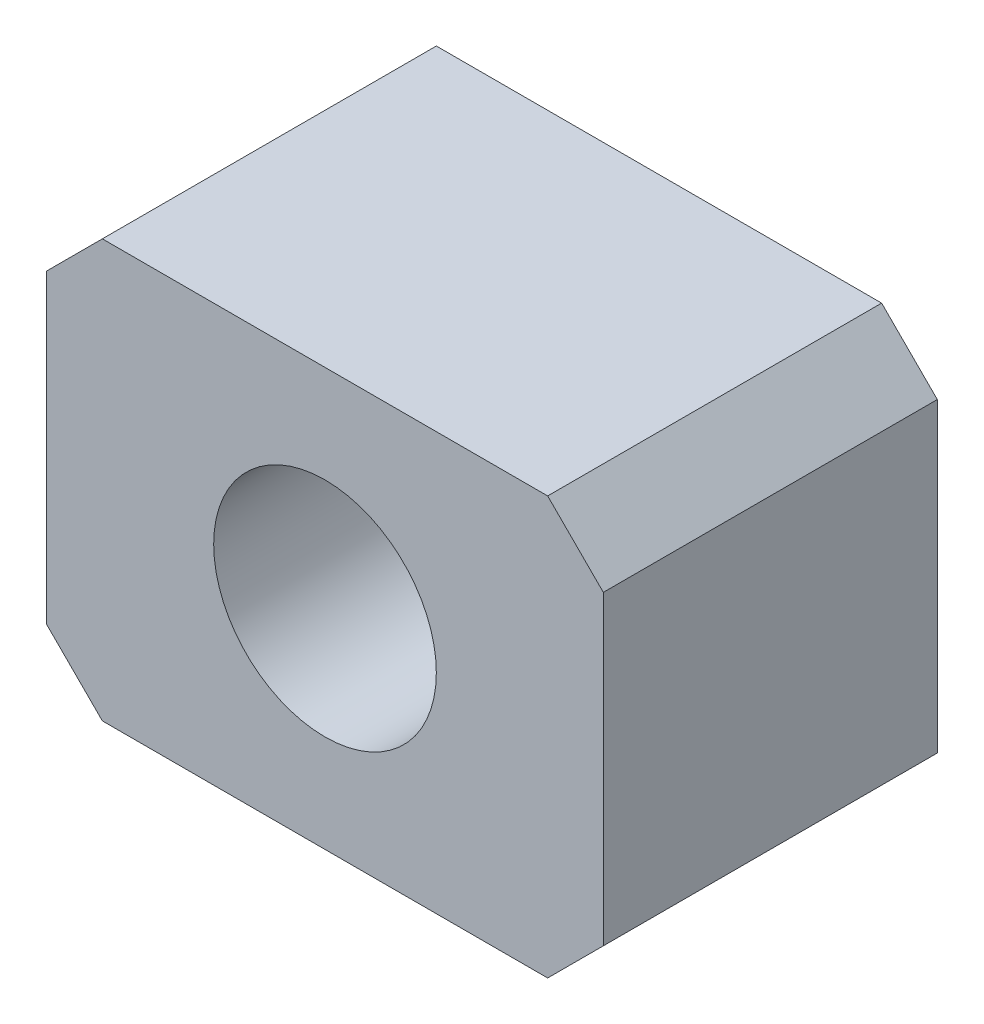
from build123d import *

# Parameters (mm, degrees)
SKETCH1_W           = 20
SKETCH1_H           = 15
BOSS_EXTRUDE1_DEPTH = 12
SKETCH2_R           = 4
CUT_EXTRUDE1_DEPTH  = 13
CHAMFER1_SIZE       = 2


with BuildPart() as part:
    # Sketch1 → Boss-Extrude1 (new body)
    with BuildSketch(Plane.XY):
        Rectangle(SKETCH1_W, SKETCH1_H)
    extrude(amount=BOSS_EXTRUDE1_DEPTH)

    # Sketch2 → Cut-Extrude1 (cut, through all)
    with BuildSketch(Plane.XY.offset(12)):
        Circle(SKETCH2_R)
    extrude(amount=-CUT_EXTRUDE1_DEPTH, mode=Mode.SUBTRACT)

    # Chamfer1
    chamfer1_edges = [part.edges().sort_by_distance(p)[0] for p in [
        (10, 7.5, 6),
        (10, -7.5, 6),
        (-10, -7.5, 6),
        (-10, 7.5, 6),
    ]]
    chamfer(chamfer1_edges, length=CHAMFER1_SIZE)


solid = part.part
